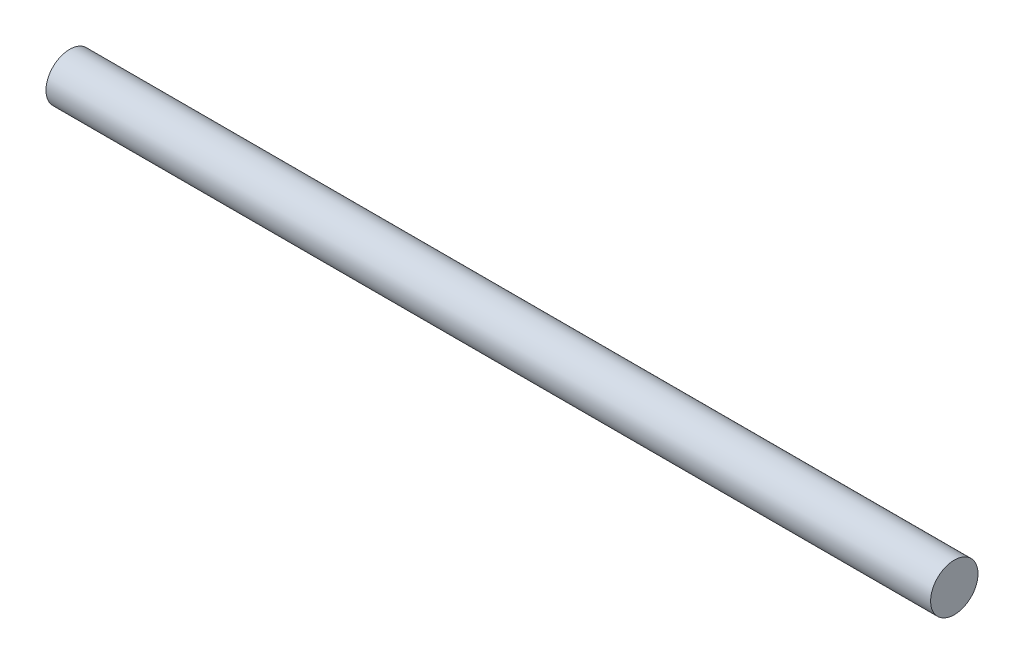
from build123d import *

# Parameters (mm, degrees)
SKETCH1_R           = 15
BOSS_EXTRUDE1_DEPTH = 560


with BuildPart() as part:
    # Sketch1 → Boss-Extrude1 (new body)
    with BuildSketch(Plane(origin=(0, 0, 0), x_dir=(0, 0, -1), z_dir=(1, 0, 0))):
        Circle(SKETCH1_R)
    extrude(amount=BOSS_EXTRUDE1_DEPTH)


solid = part.part
